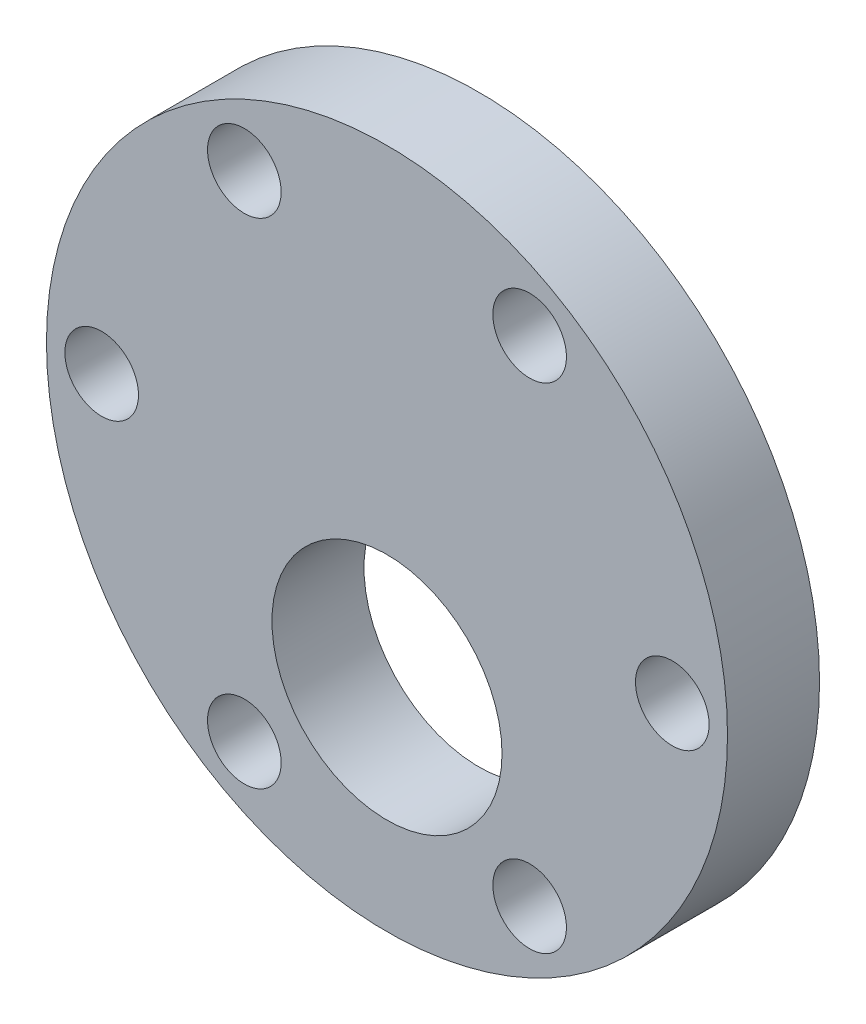
from build123d import *

# Parameters (mm, degrees)
ESQUISSE1_R             = 18.5
BOSS_EXTRU_1_DEPTH      = 5
ESQUISSE2_R             = 2
ENL_V_MAT_EXTRU_1_DEPTH = 6
ESQUISSE3_R             = 6.25
ENL_V_MAT_EXTRU_2_DEPTH = 6


with BuildPart() as part:
    # Esquisse1 → Boss.-Extru.1 (new body)
    with BuildSketch(Plane.XY):
        Circle(ESQUISSE1_R)
    extrude(amount=BOSS_EXTRU_1_DEPTH)

    # Esquisse2 → Enlèv. mat.-Extru.1 (cut, through all)
    with BuildSketch(Plane.XY.offset(5)):
        with Locations((-15.5, 0)):
            Circle(ESQUISSE2_R)
        with Locations((15.5, 0)):
            Circle(ESQUISSE2_R)
        with Locations((7.75, -13.423393759)):
            Circle(ESQUISSE2_R)
        with Locations((-7.75, -13.423393759)):
            Circle(ESQUISSE2_R)
        with Locations((-7.75, 13.423393759)):
            Circle(ESQUISSE2_R)
        with Locations((7.75, 13.423393759)):
            Circle(ESQUISSE2_R)
    extrude(amount=-ENL_V_MAT_EXTRU_1_DEPTH, mode=Mode.SUBTRACT)

    # Esquisse3 → Enlèv. mat.-Extru.2 (cut, through all)
    with BuildSketch(Plane.XY.offset(5)):
        with Locations((0, -7)):
            Circle(ESQUISSE3_R)
    extrude(amount=-ENL_V_MAT_EXTRU_2_DEPTH, mode=Mode.SUBTRACT)


solid = part.part
